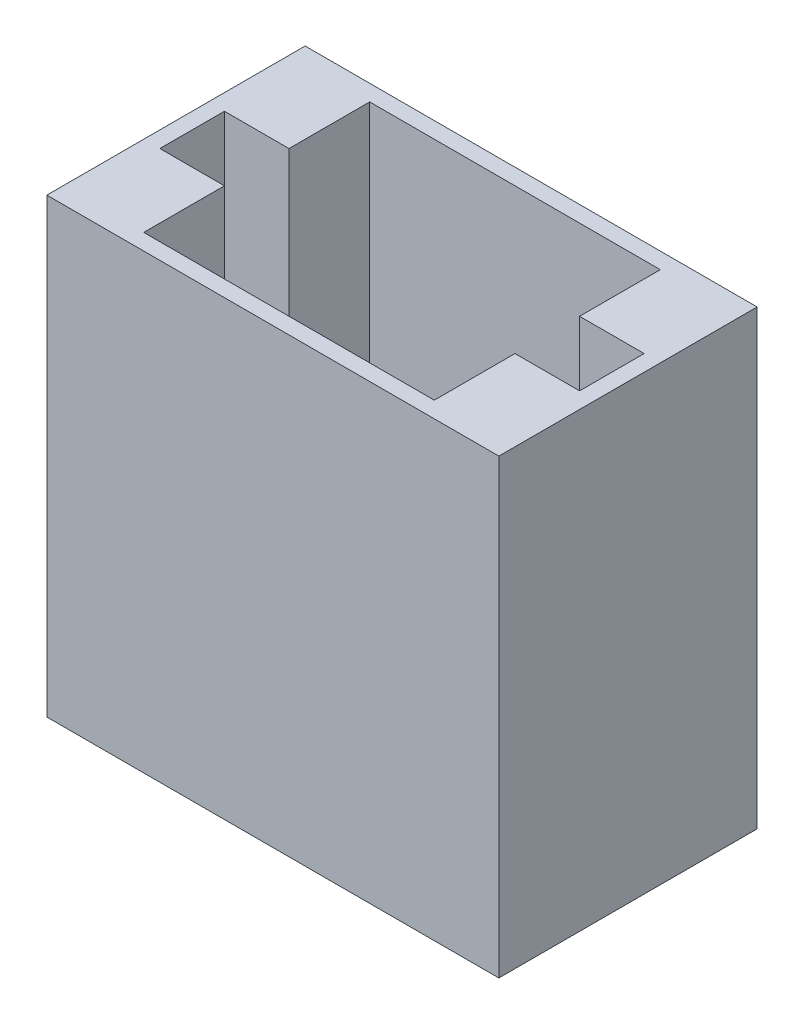
from build123d import *

# Parameters (mm, degrees)
SKETCH3_W           = 70
SKETCH3_H           = 40
BOSS_EXTRUDE2_DEPTH = 70
SKETCH4_W           = 65
SKETCH4_H           = 35
CUT_EXTRUDE1_DEPTH  = 71
SKETCH5_W           = 12.5
SKETCH5_H           = 70
BOSS_EXTRUDE3_DEPTH = 10


with BuildPart() as part:
    # Sketch3 → Boss-Extrude2 (new body)
    with BuildSketch(Plane(origin=(0, 0, 0), x_dir=(1, 0, 0), z_dir=(0, 1, 0))):
        Rectangle(SKETCH3_W, SKETCH3_H)
    extrude(amount=BOSS_EXTRUDE2_DEPTH)

    # Sketch4 → Cut-Extrude1 (cut, through all)
    with BuildSketch(Plane(origin=(0, 70, 0), x_dir=(1, 0, 0), z_dir=(0, 1, 0))):
        Rectangle(SKETCH4_W, SKETCH4_H)
    extrude(amount=-CUT_EXTRUDE1_DEPTH, mode=Mode.SUBTRACT)

    # Sketch5 → Boss-Extrude3 (add)
    with BuildSketch(Plane(origin=(-32.5, 0, 0), x_dir=(0, 0, -1), z_dir=(1, 0, 0))):
        with Locations((-11.25, 35)):
            Rectangle(SKETCH5_W, SKETCH5_H)
        with Locations((11.25, 35)):
            Rectangle(SKETCH5_W, SKETCH5_H)
    boss_extrude3 = extrude(amount=BOSS_EXTRUDE3_DEPTH)

    # Mirror1: Boss-Extrude3 across plane
    add(boss_extrude3.mirror(Plane(origin=(0, 0, 0), x_dir=(0, 0, 1), z_dir=(1, 0, 0))))


solid = part.part
